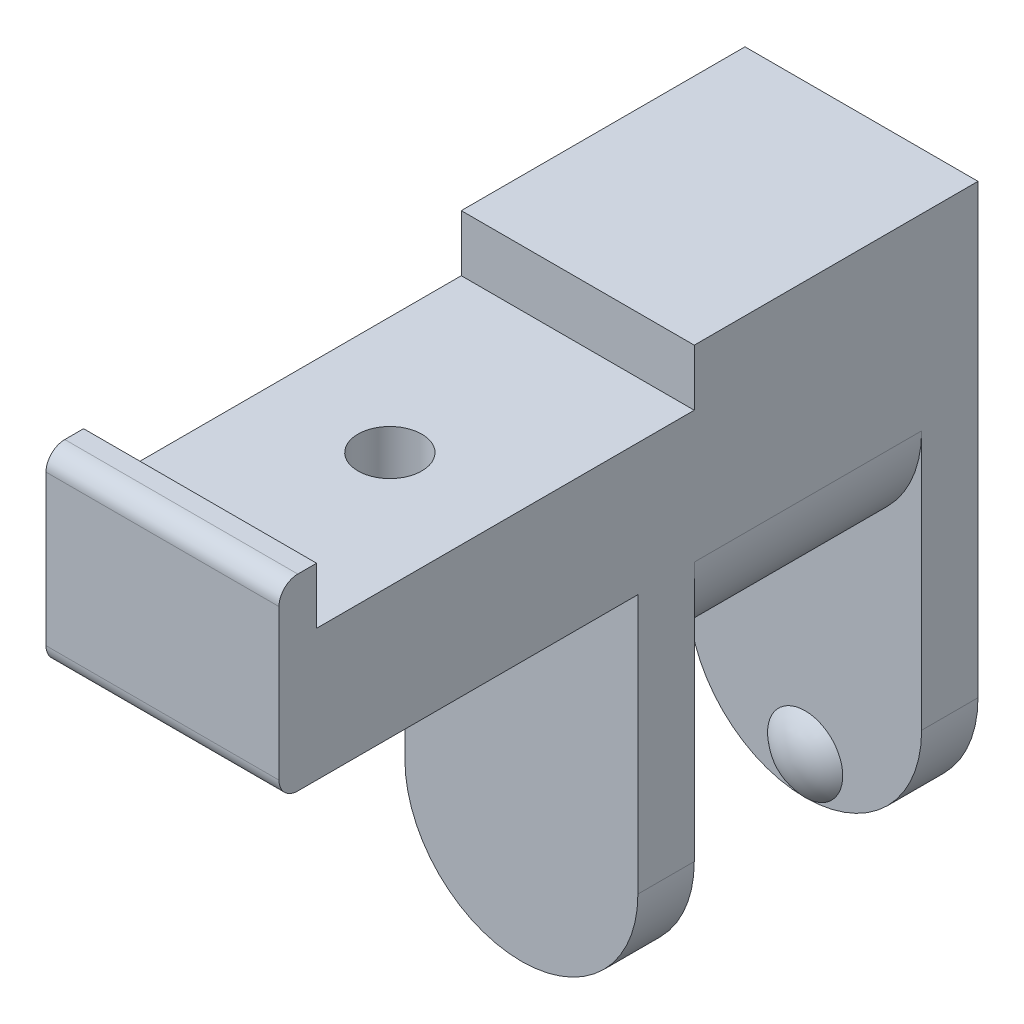
from build123d import *

# Parameters (mm, degrees)
SKETCH_2_W               = 12.1
SKETCH_2_H               = 8
EXTRUDE_1_DEPTH          = 12.4
CUT_EXTRUDE_1_DEPTH      = 12.1
CUT_EXTRUDE_2_DEPTH      = 23.1
CUT_EXTRUDE_2_DEPTH_BACK = 16.1
HOLE_WIZARD_M31_D        = 3.4
HOLE_WIZARD_M31_DEPTH    = 10
HOLE_WIZARD_M31_TIP      = 1.021463052
FILLET_1_R               = 1


with BuildPart() as part:
    # Эскиз2 → Бобышка-Вытянуть1 (new body)
    with BuildSketch(Plane(origin=(0, 0, 0), x_dir=(0, 0, -1), z_dir=(1, 0, 0))):
        Polygon((-20.1, 10), (-20.1, 7), (0, 7), (0, 10), (15.1, 10), (15.1, -20), (12.1, -20), (12.1, 0), (0, 0), (0, -20), (-3, -20), (-3, 0), (-22.1, 0), (-22.1, 10), align=None)
        with Locations((6.05, -4)):
            Rectangle(SKETCH_2_W, SKETCH_2_H)
    extrude(amount=EXTRUDE_1_DEPTH)

    # Эскиз3 → Вырез-Вытянуть1 (cut)
    with BuildSketch(Plane.XY):
        with BuildLine():
            Line((0, 0), (-4.310236897, 0))
            Line((-4.310236897, 0), (-4.310236897, -10.158248203))
            Line((-4.310236897, -10.158248203), (16.784307367, -10.158248203))
            Line((16.784307367, -10.158248203), (16.784307367, 0))
            Line((16.784307367, 0), (12.4, 0))
            ThreePointArc((12.4, 0), (6.2, -6.2), (0, 0))
        make_face()
    extrude(amount=-CUT_EXTRUDE_1_DEPTH, mode=Mode.SUBTRACT)

    # Эскиз4 → Вырез-Вытянуть2 (cut, two sides)
    with BuildSketch(Plane.XY) as cut_extrude_2_sk:
        with BuildLine():
            Line((0, -13.8), (-4.529189241, -13.8))
            Line((-4.529189241, -13.8), (-4.529189241, -23.032738442))
            Line((-4.529189241, -23.032738442), (17.457291493, -23.032738442))
            Line((17.457291493, -23.032738442), (17.457291493, -13.8))
            Line((17.457291493, -13.8), (12.4, -13.8))
            ThreePointArc((12.4, -13.8), (6.2, -20), (0, -13.8))
        make_face()
    extrude(amount=CUT_EXTRUDE_2_DEPTH, mode=Mode.SUBTRACT)
    extrude(cut_extrude_2_sk.sketch, amount=-CUT_EXTRUDE_2_DEPTH_BACK, mode=Mode.SUBTRACT)

    # Отверстие с зазором M31
    with Locations(Plane(origin=(0, 7, 0), x_dir=(1, 0, 0), z_dir=(0, 1, 0))):
        with Locations((6.25, -10.05)):
            Hole(HOLE_WIZARD_M31_D / 2, depth=HOLE_WIZARD_M31_DEPTH)
            with Locations((0, 0, -(HOLE_WIZARD_M31_DEPTH + HOLE_WIZARD_M31_TIP / 2))):  # 118° drill point
                Cone(0, HOLE_WIZARD_M31_D / 2, HOLE_WIZARD_M31_TIP, mode=Mode.SUBTRACT)

    # Скругление1
    fillet_1_edges = [part.edges().sort_by_distance(p)[0] for p in [
        (6.2, 0, 22.1),
        (6.2, 10, 22.1),
    ]]
    fillet(fillet_1_edges, radius=FILLET_1_R)

    # Эскиз9 → Повернуть1 (revolve)
    with BuildSketch(Plane(origin=(6.2, 0, 0), x_dir=(0, 0, -1), z_dir=(1, 0, 0))):
        with BuildLine():
            Line((12.1, -20), (12.1, -18))
            Line((12.1, -18), (11.3, -18))
            ThreePointArc((11.3, -18), (11.507417596, -19.077032961), (12.1, -20))
        make_face()
    revolve(axis=Axis((6.2, -18, -11.3), (0, 0, -1)))


solid = part.part
